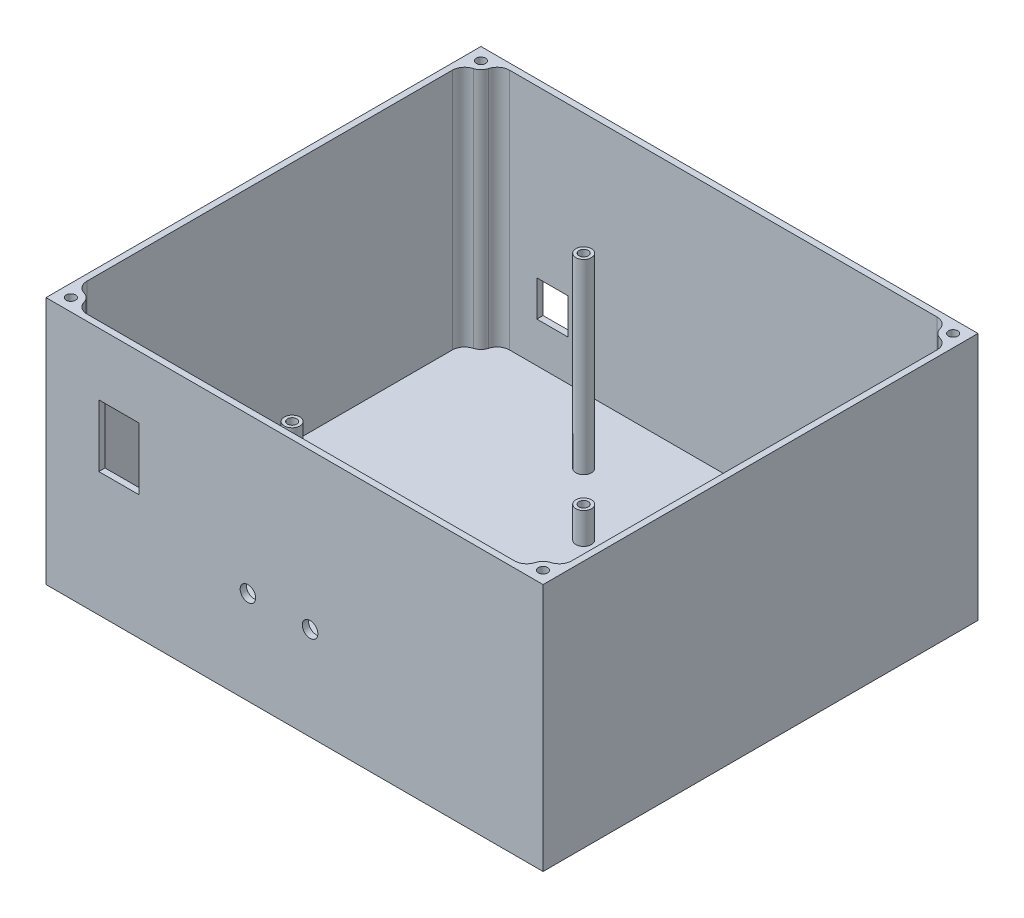
from build123d import *

# Parameters (mm, degrees)
SKETCH1_W                 = 160
SKETCH1_H                 = 140
BOSS_EXTRUDE1_DEPTH       = 80
F_3_0MM_DOWEL_HOLE3_D     = 3
SHELL1_T                  = -2
SKETCH10_R                = 2.5
BOSS_EXTRUDE3_DEPTH       = 60
F_3_0MM_DOWEL_HOLE2_D     = 3
F_3_0MM_DOWEL_HOLE2_DEPTH = 45
F_3_0MM_DOWEL_HOLE2_TIP   = 0.901290929
FILLET1_R                 = 4
SKETCH15_R                = 2.5
BOSS_EXTRUDE5_DEPTH       = 10
F_3_0MM_DOWEL_HOLE5_D     = 3
SKETCH20_W                = 13
SKETCH20_H                = 20
CUT_EXTRUDE1_DEPTH        = 2
F_5_0MM_DOWEL_HOLE1_D     = 5
F_5_0MM_DOWEL_HOLE1_DEPTH = 2
SKETCH27_W                = 10
SKETCH27_H                = 11.5
CUT_EXTRUDE2_DEPTH        = 2


with BuildPart() as part:
    # Sketch1 → Boss-Extrude1 (new body)
    with BuildSketch(Plane(origin=(0, 0, 0), x_dir=(1, 0, 0), z_dir=(0, 1, 0))):
        Rectangle(SKETCH1_W, SKETCH1_H)
    extrude(amount=BOSS_EXTRUDE1_DEPTH)

    # Ø3.0mm Dowel Hole3 (through all)
    with Locations(Plane(origin=(0, 80, 0), x_dir=(1, 0, 0), z_dir=(0, 1, 0))):
        with Locations((-76, 66), (76, 66), (76, -66), (-76, -66)):
            Hole(F_3_0MM_DOWEL_HOLE3_D / 2)

    # Shell1
    shell1_openings = [part.faces().sort_by_distance(p)[0] for p in [
        (-76, 80, -64.5),
    ]]
    offset(amount=SHELL1_T, openings=shell1_openings, kind=Kind.INTERSECTION)

    # Sketch10 → Boss-Extrude3 (add)
    with BuildSketch(Plane(origin=(0, 2, 0), x_dir=(1, 0, 0), z_dir=(0, 1, 0))):
        with Locations((70, 46.925)):
            Circle(SKETCH10_R)
        with Locations((-23.85, 46.925)):
            Circle(SKETCH10_R)
        with Locations((-23.85, -46.925)):
            Circle(SKETCH10_R)
        with Locations((70, -46.925)):
            Circle(SKETCH10_R)
    extrude(amount=BOSS_EXTRUDE3_DEPTH)

    # Ø3.0mm Dowel Hole2
    with Locations(Plane(origin=(0, 62, 0), x_dir=(1, 0, 0), z_dir=(0, 1, 0))):
        with Locations((-23.85, 46.925), (70, 46.925), (70, -46.925), (-23.85, -46.925)):
            Hole(F_3_0MM_DOWEL_HOLE2_D / 2, depth=F_3_0MM_DOWEL_HOLE2_DEPTH)
            with Locations((0, 0, -(F_3_0MM_DOWEL_HOLE2_DEPTH + F_3_0MM_DOWEL_HOLE2_TIP / 2))):  # 118° drill point
                Cone(0, F_3_0MM_DOWEL_HOLE2_D / 2, F_3_0MM_DOWEL_HOLE2_TIP, mode=Mode.SUBTRACT)

    # Fillet1
    fillet1_edges = [part.edges().sort_by_distance(p)[0] for p in [
        (78, 41, 63.127718677),
        (73.127718677, 41, -68),
        (-78, 41, -63.127718677),
        (-73.127718677, 41, 68),
        (-78, 41, 63.127718677),
        (73.127718677, 41, 68),
        (78, 41, -63.127718677),
        (-73.127718677, 41, -68),
    ]]
    fillet(fillet1_edges, radius=FILLET1_R)

    # Sketch15 → Boss-Extrude5 (add)
    with BuildSketch(Plane(origin=(0, 2, 0), x_dir=(1, 0, 0), z_dir=(0, 1, 0))):
        with Locations((-3.85, 26.925)):
            Circle(SKETCH15_R)
        with Locations((50, 26.925)):
            Circle(SKETCH15_R)
        with Locations((-3.85, -26.925)):
            Circle(SKETCH15_R)
        with Locations((50, -26.925)):
            Circle(SKETCH15_R)
    extrude(amount=BOSS_EXTRUDE5_DEPTH)

    # Ø3.0mm Dowel Hole5 (through all)
    with Locations(Plane(origin=(0, 12, 0), x_dir=(1, 0, 0), z_dir=(0, 1, 0))):
        with Locations((-3.85, 26.925), (50, 26.925), (50, -26.925), (-3.85, -26.925)):
            Hole(F_3_0MM_DOWEL_HOLE5_D / 2)

    # Sketch20 → Cut-Extrude1 (cut)
    with BuildSketch(Plane.XY.offset(70)):
        with Locations((-56.5, 50)):
            Rectangle(SKETCH20_W, SKETCH20_H)
    extrude(amount=-CUT_EXTRUDE1_DEPTH, mode=Mode.SUBTRACT)

    # Ø5.0mm Dowel Hole1
    with Locations(Plane.XY.offset(70)):
        with Locations((-15, 30), (5, 30)):
            Hole(F_5_0MM_DOWEL_HOLE1_D / 2, depth=F_5_0MM_DOWEL_HOLE1_DEPTH)

    # Sketch27 → Cut-Extrude2 (cut)
    with BuildSketch(Plane(origin=(0, 0, -70), x_dir=(-1, 0, 0), z_dir=(0, 0, -1))):
        with Locations((55, 20.75)):
            Rectangle(SKETCH27_W, SKETCH27_H)
    extrude(amount=-CUT_EXTRUDE2_DEPTH, mode=Mode.SUBTRACT)


solid = part.part
